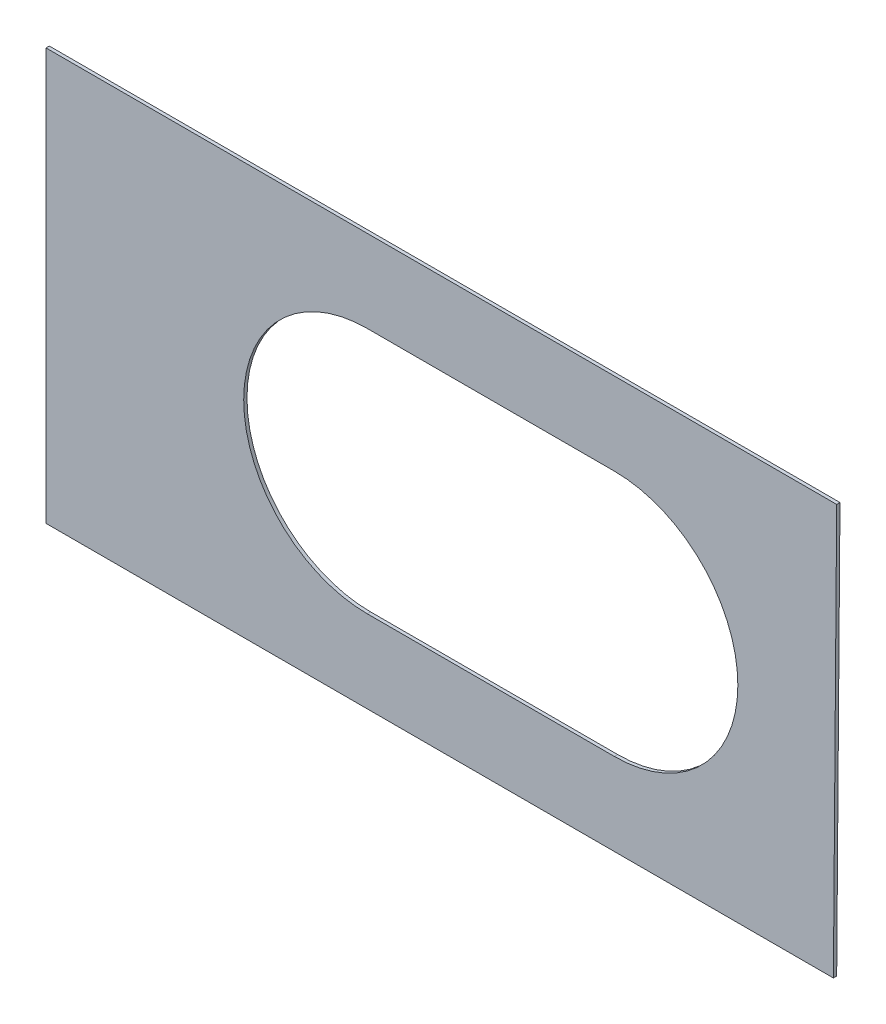
from build123d import *

# Parameters (mm, degrees)
BOSS_EXTRUDE1_DEPTH = 2


with BuildPart() as part:
    # Model → Boss-Extrude1 (new body)
    with BuildSketch(Plane.XY):
        Polygon((-240, 125), (240, 125), (238, -125), (-240, -125), align=None)
        with BuildLine():
            Line((-45, 75), (105, 75))
            ThreePointArc((105, 75), (180, 0), (105, -75))
            Line((105, -75), (-45, -75))
            ThreePointArc((-45, -75), (-120, 0), (-45, 75))
        make_face(mode=Mode.SUBTRACT)
    extrude(amount=BOSS_EXTRUDE1_DEPTH)


solid = part.part
